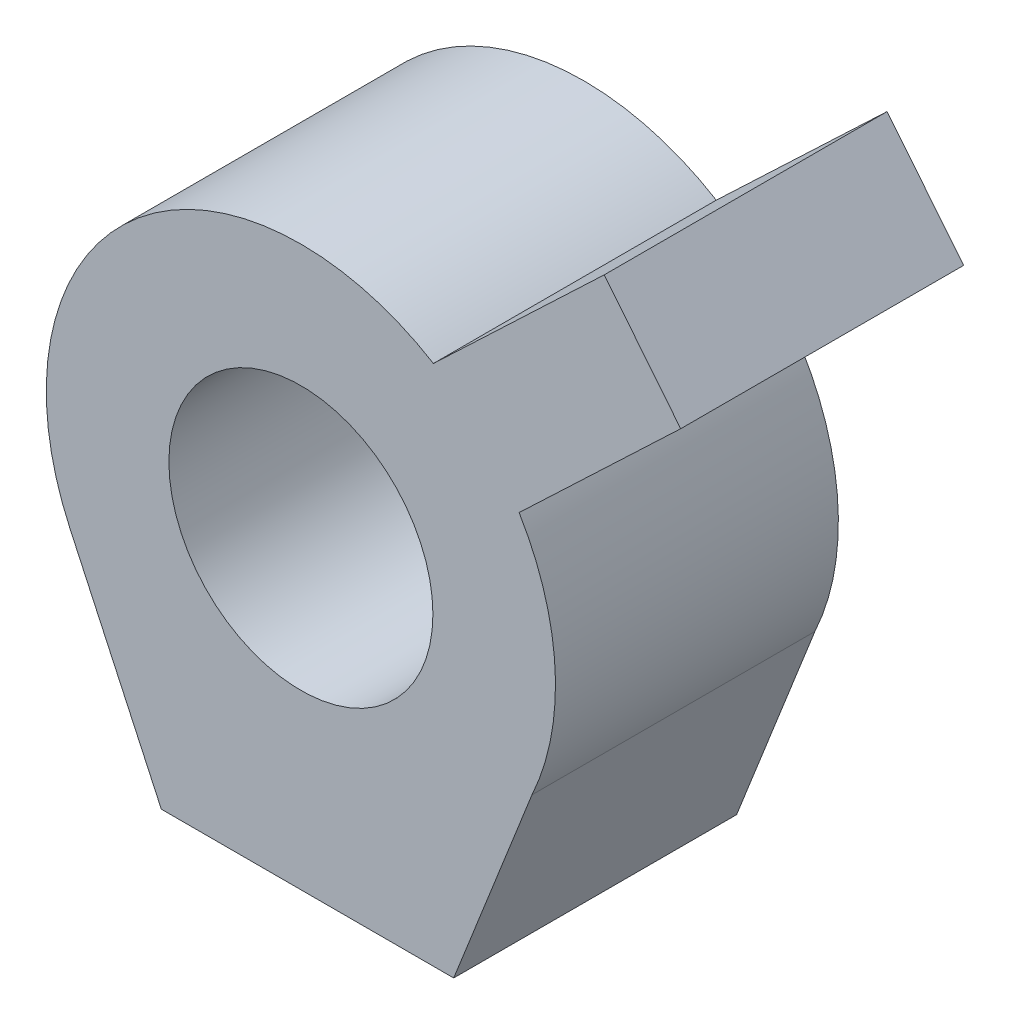
from build123d import *

# Parameters (mm, degrees)
SKETCH1_R           = 11.1125
BOSS_EXTRUDE1_DEPTH = 23.8125


with BuildPart() as part:
    # Sketch1 → Boss-Extrude1 (new body)
    with BuildSketch(Plane.XY):
        with BuildLine():
            Line((-19.45060256, -8.998474127), (-11.749724448, -25.644265115))
            Line((-11.749724448, -25.644265115), (12.863242985, -25.644265115))
            Line((12.863242985, -25.644265115), (19.45060256, -8.998474127))
            ThreePointArc((19.45060256, -8.998474127), (21.400108774, 1.154911696), (18.369201048, 11.039516721))
            Line((18.369201048, 11.039516721), (31.970540917, 23.950858732))
            Line((31.970540917, 23.950858732), (25.535140583, 31.951663088))
            Line((25.535140583, 31.951663088), (11.153892049, 18.299977287))
            ThreePointArc((11.153892049, 18.299977287), (-14.265700604, 15.993381845), (-19.45060256, -8.998474127))
        make_face()
        Circle(SKETCH1_R, mode=Mode.SUBTRACT)
    extrude(amount=BOSS_EXTRUDE1_DEPTH)


solid = part.part
